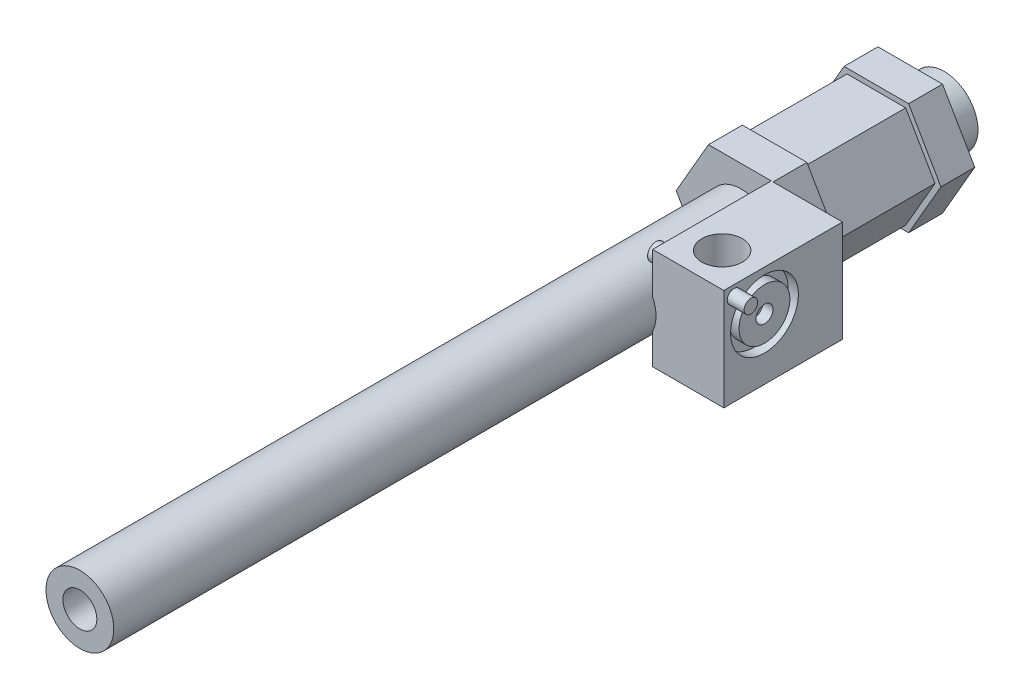
from build123d import *

# Parameters (mm, degrees)
SKETCH1_R            = 10
BOSS_EXTRUDE1_DEPTH  = 255
SKETCH2_R            = 5
CUT_EXTRUDE1_DEPTH   = 250
BOSS_EXTRUDE2_START  = -10
SKETCH3_R            = 10
BOSS_EXTRUDE2_DEPTH  = 50
BOSS_EXTRUDE3_DEPTH  = 10
BOSS_EXTRUDE4_START  = -40
BOSS_EXTRUDE4_DEPTH  = 10
BOSS_EXTRUDE6_START  = 10
SKETCH5_W            = 35
SKETCH5_H            = 30
BOSS_EXTRUDE6_DEPTH  = 10
SKETCH6_W            = 35
SKETCH6_H            = 30
BOSS_EXTRUDE8_DEPTH  = 11
SKETCH7_R            = 6
CUT_EXTRUDE2_DEPTH   = 21
SKETCH8_R            = 2.5
BOSS_EXTRUDE9_DEPTH  = 4
SKETCH9_R            = 10
SKETCH9_R_2          = 7.5
SKETCH9_R_3          = 2.5
CUT_EXTRUDE3_DEPTH   = 3
SKETCH10_R           = 2
BOSS_EXTRUDE10_DEPTH = 5


with BuildPart() as part:
    # Sketch1 → Boss-Extrude1 (new body)
    with BuildSketch(Plane.XY):
        Circle(SKETCH1_R)
    extrude(amount=BOSS_EXTRUDE1_DEPTH)

    # Sketch2 → Cut-Extrude1 (cut)
    with BuildSketch(Plane.XY.offset(255)):
        Circle(SKETCH2_R)
    extrude(amount=-CUT_EXTRUDE1_DEPTH, mode=Mode.SUBTRACT)

    # Sketch3 → Boss-Extrude2 (add)
    with BuildSketch(Plane(origin=(0, 0, 0), x_dir=(-1, 0, 0), z_dir=(0, 0, -1)).offset(BOSS_EXTRUDE2_START)):
        Polygon((17.320508076, 0), (8.660254038, 15), (-8.660254038, 15), (-17.320508076, 0), (-8.660254038, -15), (8.660254038, -15), align=None)
        Circle(SKETCH3_R, mode=Mode.SUBTRACT)
    extrude(amount=-BOSS_EXTRUDE2_DEPTH)

    # Sketch4 → Boss-Extrude3 (add)
    with BuildSketch(Plane(origin=(0, 0, 10), x_dir=(-1, 0, 0), z_dir=(0, 0, -1))):
        Polygon((-9.526279442, -16.5), (9.526279442, -16.5), (19.052558883, 0), (9.526279442, 16.5), (-9.526279442, 16.5), (-19.052558883, 0), align=None)
        Polygon((8.660254038, 15), (-8.660254038, 15), (-17.320508076, 0), (-8.660254038, -15), (8.660254038, -15), (17.320508076, 0), align=None, mode=Mode.SUBTRACT)
    extrude(amount=-BOSS_EXTRUDE3_DEPTH)

    # Sketch4_2 → Boss-Extrude4 (add)
    with BuildSketch(Plane(origin=(0, 0, 10), x_dir=(-1, 0, 0), z_dir=(0, 0, -1)).offset(BOSS_EXTRUDE4_START)):
        Polygon((-9.526279442, -16.5), (9.526279442, -16.5), (19.052558883, 0), (9.526279442, 16.5), (-9.526279442, 16.5), (-19.052558883, 0), align=None)
        Polygon((8.660254038, 15), (-8.660254038, 15), (-17.320508076, 0), (-8.660254038, -15), (8.660254038, -15), (17.320508076, 0), align=None, mode=Mode.SUBTRACT)
    extrude(amount=-BOSS_EXTRUDE4_DEPTH)



with BuildPart() as body_2:
    # Sketch5 → Boss-Extrude6 (new body)
    with BuildSketch(Plane(origin=(10, 0, 0), x_dir=(0, 0, -1), z_dir=(1, 0, 0)).offset(BOSS_EXTRUDE6_START)):
        with Locations((-77.5, 1.5)):
            Rectangle(SKETCH5_W, SKETCH5_H)
    extrude(amount=BOSS_EXTRUDE6_DEPTH)


with BuildPart() as part_1:
    add(part.part)

    add(body_2.part)  # Boss-Extrude8 merges body 2
    # Sketch6 → Boss-Extrude8 (add)
    with BuildSketch(Plane.ZY.offset(-20)):
        with Locations((77.5, 1.5)):
            Rectangle(SKETCH6_W, SKETCH6_H)
    extrude(amount=BOSS_EXTRUDE8_DEPTH)

    # Sketch7 → Cut-Extrude2 (cut)
    with BuildSketch(Plane(origin=(0, 16.5, 0), x_dir=(1, 0, 0), z_dir=(0, 1, 0))):
        with Locations((19.5, -85)):
            Circle(SKETCH7_R)
    extrude(amount=-CUT_EXTRUDE2_DEPTH, mode=Mode.SUBTRACT)

    # Sketch8 → Boss-Extrude9 (add)
    with BuildSketch(Plane.ZY.offset(-9)):
        with Locations((90, 11.5)):
            Circle(SKETCH8_R)
    extrude(amount=BOSS_EXTRUDE9_DEPTH)

    # Sketch9 → Cut-Extrude3 (cut)
    # profile 1 of 2: a face of its own
    with BuildSketch(Plane(origin=(30, 0, 0), x_dir=(0, 0, -1), z_dir=(1, 0, 0))):
        with Locations((-83, 4.5)):
            Circle(SKETCH9_R)
        with Locations((-83, 4.5)):
            Circle(SKETCH9_R_2, mode=Mode.SUBTRACT)
    # profile 2 of 2: a face of its own
    with BuildSketch(Plane(origin=(30, 0, 0), x_dir=(0, 0, -1), z_dir=(1, 0, 0))):
        with Locations((-83, 4.5)):
            Circle(SKETCH9_R_3)
    extrude(amount=-CUT_EXTRUDE3_DEPTH, mode=Mode.SUBTRACT)

    # Sketch10 → Boss-Extrude10 (add)
    with BuildSketch(Plane(origin=(30, 0, 0), x_dir=(0, 0, -1), z_dir=(1, 0, 0))):
        with Locations((-92, 13.5)):
            Circle(SKETCH10_R)
    extrude(amount=BOSS_EXTRUDE10_DEPTH)


solid = part_1.part
